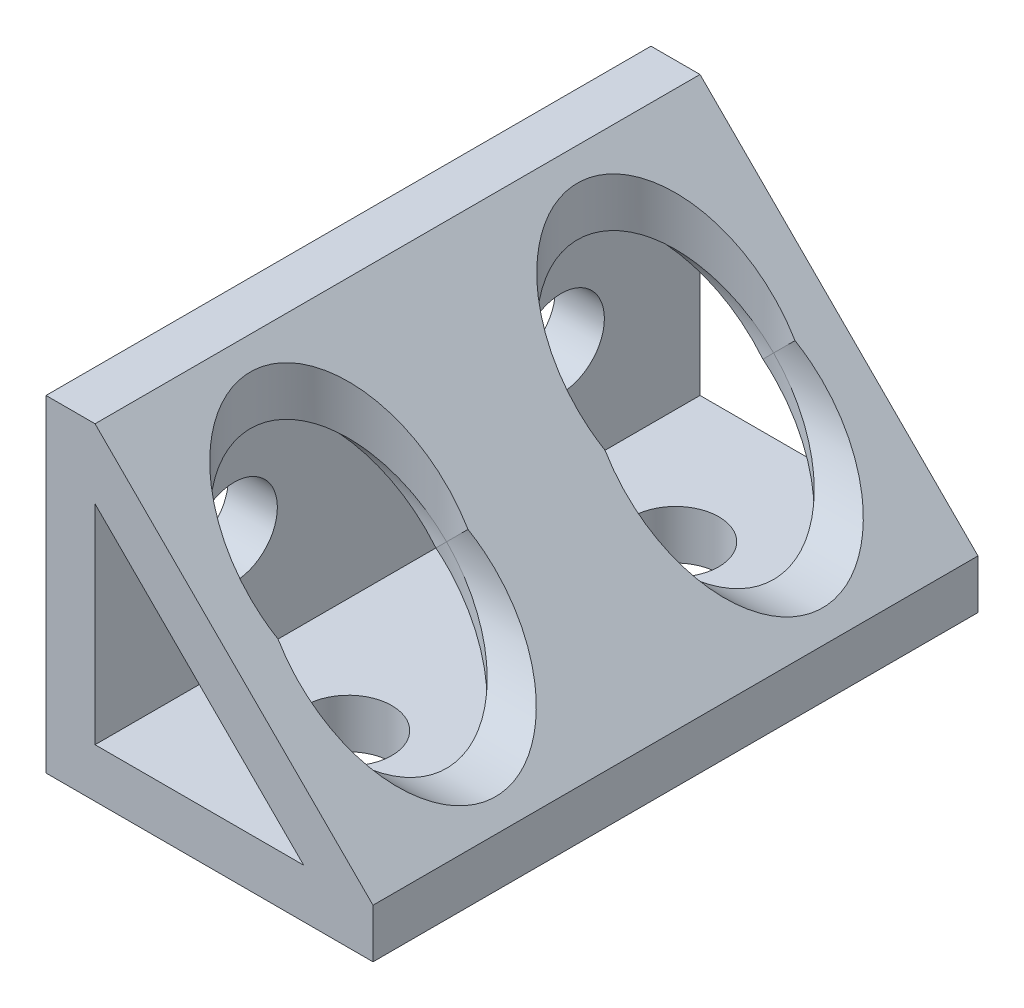
from build123d import *

# Parameters (mm, degrees)
BOSS_EXTRUDE1_DEPTH     = 18.5
SKETCH4_R               = 2.65
CUT_EXTRUDE1_DEPTH      = 3
SKETCH6_R               = 6
CUT_EXTRUDE2_DEPTH      = 18
MIRROR2_COPY_1_SKETCH_R = 2.65
MIRROR2_COPY_1_DEPTH    = 3
MIRROR2_COPY_2_SKETCH_R = 6
MIRROR2_COPY_2_DEPTH    = 18
MIRROR2_COPY_3_SKETCH_R = 2.65
MIRROR2_COPY_3_DEPTH    = 3


with BuildPart() as part:
    # Sketch2 → Boss-Extrude1 (new body, symmetric)
    with BuildSketch(Plane.XY):
        Polygon((-10, 10), (-10, -10), (10, -10), (10, -7), (-7, 10), align=None)
        Polygon((-7, 5.757359313), (-7, -7), (5.757359313, -7), align=None, mode=Mode.SUBTRACT)
    extrude(amount=BOSS_EXTRUDE1_DEPTH, both=True)

    # Sketch4 → Cut-Extrude1 (cut)
    with BuildSketch(Plane.XZ.offset(10)):
        with Locations((0, -10)):
            Circle(SKETCH4_R)
        with Locations((0, 10)):
            Circle(SKETCH4_R)
    cut_extrude1 = extrude(amount=-CUT_EXTRUDE1_DEPTH, mode=Mode.SUBTRACT)

    # Sketch6 → Cut-Extrude2 (cut, through all)
    with BuildSketch(Plane(origin=(0, -7, 0), x_dir=(1, 0, 0), z_dir=(0, 1, 0))):
        with Locations((0, -10)):
            Circle(SKETCH6_R)
    cut_extrude2 = extrude(amount=CUT_EXTRUDE2_DEPTH, mode=Mode.SUBTRACT)

    # Mirror1: Cut-Extrude1, Cut-Extrude2 across plane
    add(cut_extrude1.mirror(Plane(origin=(0, 0, 0), x_dir=(0, 0, 1), z_dir=(0.707106781, -0.707106781, 0))), mode=Mode.SUBTRACT)
    add(cut_extrude2.mirror(Plane(origin=(0, 0, 0), x_dir=(0, 0, 1), z_dir=(0.707106781, -0.707106781, 0))), mode=Mode.SUBTRACT)

    # Mirror2: Cut-Extrude2 across plane
    add(cut_extrude2.mirror(Plane.XY), mode=Mode.SUBTRACT)

    # Mirror2 copy 1 sketch → Mirror2 copy 1 (cut)
    with BuildSketch(Plane(origin=(-10, 0, 0), x_dir=(0, 1, 0), z_dir=(-1, 0, 0))):
        with Locations((0, -10)):
            Circle(MIRROR2_COPY_1_SKETCH_R)
        with Locations((0, 10)):
            Circle(MIRROR2_COPY_1_SKETCH_R)
    extrude(amount=-MIRROR2_COPY_1_DEPTH, mode=Mode.SUBTRACT)

    # Mirror2 copy 2 sketch → Mirror2 copy 2 (cut, through all)
    with BuildSketch(Plane.YZ.offset(-7)):
        with Locations((0, -10)):
            Circle(MIRROR2_COPY_2_SKETCH_R)
    extrude(amount=MIRROR2_COPY_2_DEPTH, mode=Mode.SUBTRACT)

    # Mirror2 copy 3 sketch → Mirror2 copy 3 (cut)
    with BuildSketch(Plane.XZ.offset(10)):
        with Locations((0, 10)):
            Circle(MIRROR2_COPY_3_SKETCH_R)
        with Locations((0, -10)):
            Circle(MIRROR2_COPY_3_SKETCH_R)
    extrude(amount=-MIRROR2_COPY_3_DEPTH, mode=Mode.SUBTRACT)


solid = part.part
